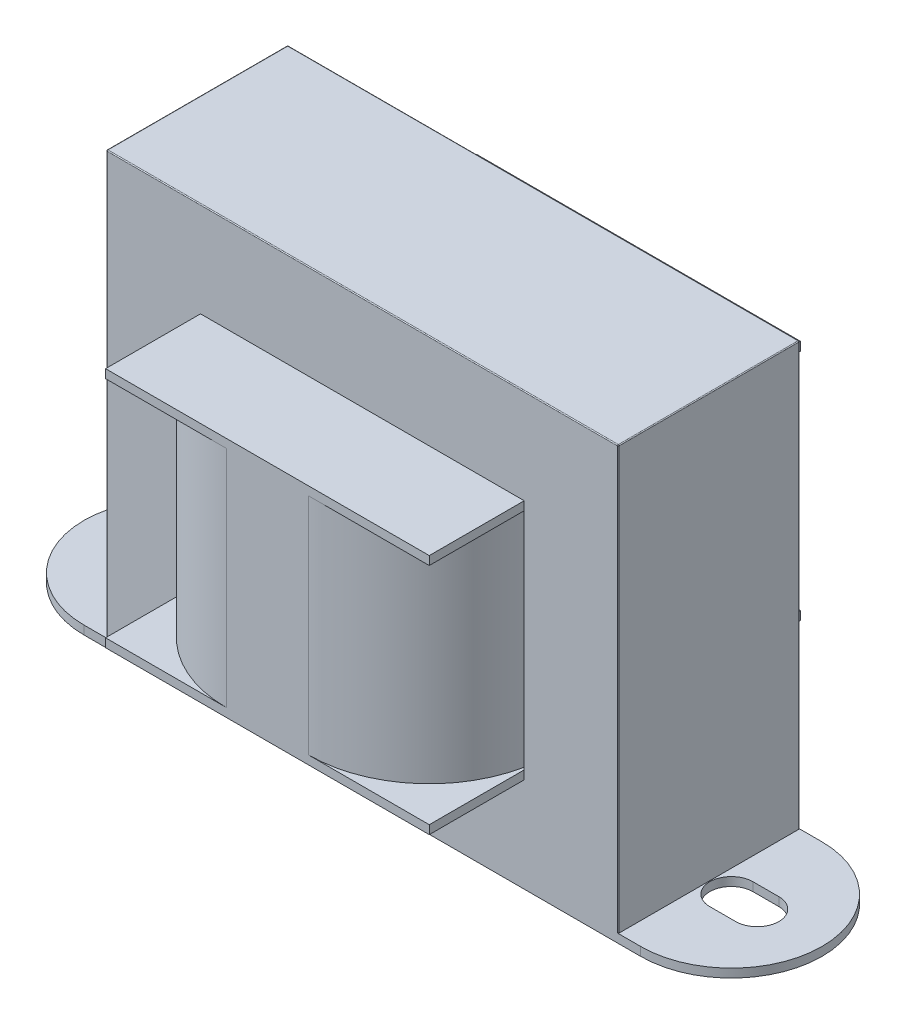
from build123d import *

# Parameters (mm, degrees)
SKETCH1_W           = 59.3
SKETCH1_H           = 48.97
BASE_EXTRUDE_DEPTH  = 10.5
BOSS_EXTRUDE1_DEPTH = 1
CUT_EXTRUDE1_DEPTH  = 10
BOSS_EXTRUDE2_DEPTH = 13
CUT_EXTRUDE2_DEPTH  = 13
SKETCH6_W           = 37.5
SKETCH6_H           = 43
BOSS_EXTRUDE3_DEPTH = 1
SKETCH7_W           = 37.5
SKETCH7_H           = 43
BOSS_EXTRUDE4_DEPTH = 1
FILLET1_R           = 0.1


with BuildPart() as part:
    # Sketch1 → Base-Extrude (new body, symmetric)
    with BuildSketch(Plane.XY):
        with Locations((32.25, 25.485)):
            Rectangle(SKETCH1_W, SKETCH1_H)
    extrude(amount=BASE_EXTRUDE_DEPTH, both=True)

    # Sketch2 → Boss-Extrude1 (add)
    with BuildSketch(Plane.XZ.offset(-1)):
        with BuildLine():
            Line((0, 10.5), (64.5, 10.5))
            ThreePointArc((64.5, 10.5), (75, 0), (64.5, -10.5))
            Line((64.5, -10.5), (0, -10.5))
            ThreePointArc((0, -10.5), (-10.5, 0), (0, 10.5))
        make_face()
    extrude(amount=BOSS_EXTRUDE1_DEPTH)

    # Sketch3 → Cut-Extrude1 (cut)
    with BuildSketch(Plane.XZ):
        with BuildLine():
            Line((64.5, 2.5), (67.5, 2.5))
            ThreePointArc((67.5, 2.5), (70, 0), (67.5, -2.5))
            Line((67.5, -2.5), (64.5, -2.5))
            ThreePointArc((64.5, -2.5), (62, 0), (64.5, 2.5))
        make_face()
        with BuildLine():
            Line((-3, 2.5), (0, 2.5))
            ThreePointArc((0, 2.5), (2.5, 0), (0, -2.5))
            Line((0, -2.5), (-3, -2.5))
            ThreePointArc((-3, -2.5), (-5.5, 0), (-3, 2.5))
        make_face()
    extrude(amount=-CUT_EXTRUDE1_DEPTH, mode=Mode.SUBTRACT)

    # Sketch4 → Boss-Extrude2 (add, symmetric)
    with BuildSketch(Plane(origin=(0, 24.97, 0), x_dir=(-1, 0, 0), z_dir=(0, 1, 0))):
        with BuildLine():
            Line((-37, 21.5), (-27.5, 21.5))
            ThreePointArc((-27.5, 21.5), (-17.600505063, 17.399494937), (-13.5, 7.5))
            Line((-13.5, 7.5), (-13.5, -7.5))
            ThreePointArc((-13.5, -7.5), (-17.600505063, -17.399494937), (-27.5, -21.5))
            Line((-27.5, -21.5), (-37, -21.5))
            ThreePointArc((-37, -21.5), (-46.899494937, -17.399494937), (-51, -7.5))
            Line((-51, -7.5), (-51, 7.5))
            ThreePointArc((-51, 7.5), (-46.899494937, 17.399494937), (-37, 21.5))
        make_face()
    extrude(amount=BOSS_EXTRUDE2_DEPTH, both=True)

    # Sketch5 → Cut-Extrude2 (cut, symmetric)
    with BuildSketch(Plane(origin=(0, 24.97, 0), x_dir=(-1, 0, 0), z_dir=(0, 1, 0))):
        with BuildLine():
            Line((-13.5, 10.5), (-13.825205669, 10.5))
            ThreePointArc((-13.825205669, 10.5), (-13.581538867, 9.008787487), (-13.5, 7.5))
            Line((-13.5, 7.5), (-13.5, 10.5))
        make_face()
        with BuildLine():
            Line((-51, 10.5), (-50.674794331, 10.5))
            ThreePointArc((-50.674794331, 10.5), (-50.918461133, 9.008787487), (-51, 7.5))
            Line((-51, 7.5), (-51, 10.5))
        make_face()
        with BuildLine():
            Line((-51, -10.5), (-50.674794331, -10.5))
            ThreePointArc((-50.674794331, -10.5), (-50.918461133, -9.008787487), (-51, -7.5))
            Line((-51, -7.5), (-51, -10.5))
        make_face()
        with BuildLine():
            Line((-13.5, -10.5), (-13.825205669, -10.5))
            ThreePointArc((-13.825205669, -10.5), (-13.581538867, -9.008787487), (-13.5, -7.5))
            Line((-13.5, -7.5), (-13.5, -10.5))
        make_face()
    extrude(amount=CUT_EXTRUDE2_DEPTH, both=True, mode=Mode.SUBTRACT)

    # Sketch6 → Boss-Extrude3 (add)
    with BuildSketch(Plane(origin=(0, 37.97, 0), x_dir=(-1, 0, 0), z_dir=(0, 1, 0))):
        with Locations((-32.25, 0)):
            Rectangle(SKETCH6_W, SKETCH6_H)
    extrude(amount=BOSS_EXTRUDE3_DEPTH)

    # Sketch7 → Boss-Extrude4 (add)
    with BuildSketch(Plane.XZ.offset(-11.97)):
        with Locations((32.25, 0)):
            Rectangle(SKETCH7_W, SKETCH7_H)
    extrude(amount=BOSS_EXTRUDE4_DEPTH)

    # Fillet1
    fillet1_edges = [part.edges().sort_by_distance(p)[0] for p in [
        (61.9, 25.485, 10.5),
        (32.25, 49.97, 10.5),
        (2.6, 25.485, 10.5),
        (32.25, 49.97, -10.5),
        (61.9, 25.485, -10.5),
        (2.6, 25.485, -10.5),
        (2.6, 49.97, 0),
        (61.9, 49.97, 0),
    ]]
    fillet(fillet1_edges, radius=FILLET1_R)


solid = part.part
